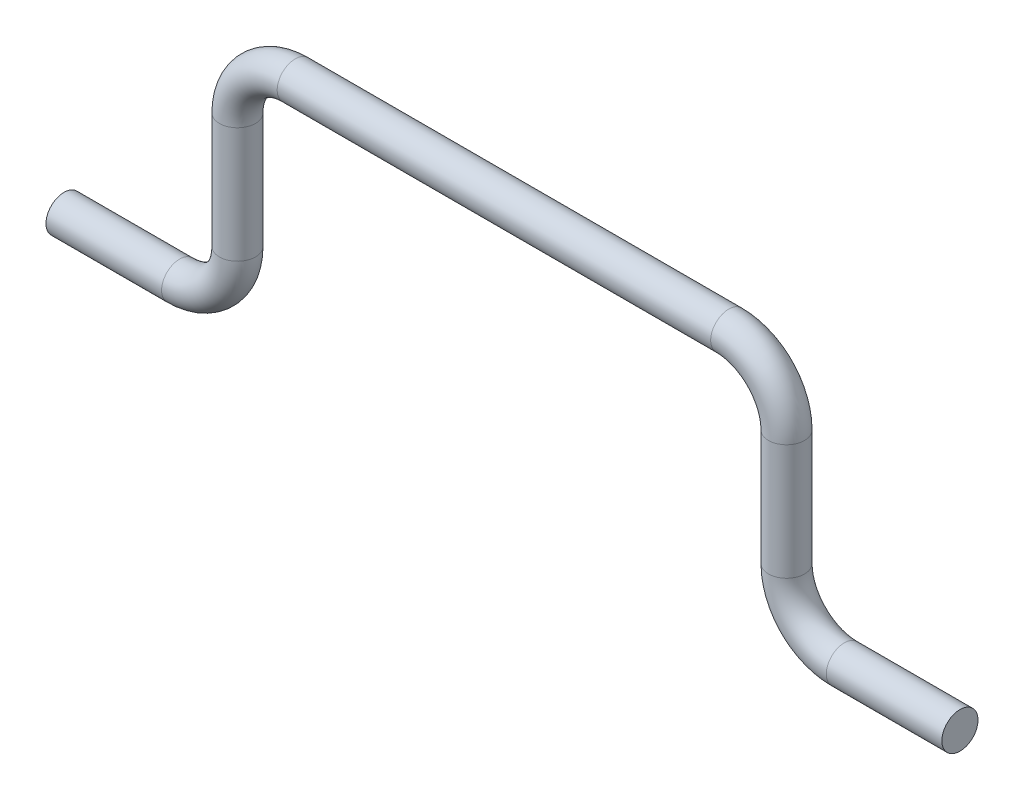
from build123d import *

# Parameters (mm, degrees)
SKETCH3_R = 3.96875


with BuildPart() as part:
    # Sweep1: sweep along a path in Sketch4
    with BuildLine(Plane.XY) as sweep1_path:
        Line((0, 0), (25.4, 0))
        ThreePointArc((25.4, 0), (34.380256121, 3.719743879), (38.1, 12.7))
        Line((38.1, 12.7), (38.1, 38.1))
        ThreePointArc((38.1, 38.1), (41.819743879, 47.080256121), (50.8, 50.8))
        Line((50.8, 50.8), (146.05, 50.8))
        ThreePointArc((146.05, 50.8), (155.030256121, 47.080256121), (158.75, 38.1))
        Line((158.75, 38.1), (158.75, 12.7))
        ThreePointArc((158.75, 12.7), (162.469743879, 3.719743879), (171.45, 0))
        Line((171.45, 0), (196.85, 0))
    # Sketch3 → Sweep1 (sweep)
    with BuildSketch(Plane(origin=(0, 0, 0), x_dir=(0, 0, -1), z_dir=(1, 0, 0))):
        Circle(SKETCH3_R)
    sweep(path=sweep1_path.line)


solid = part.part
